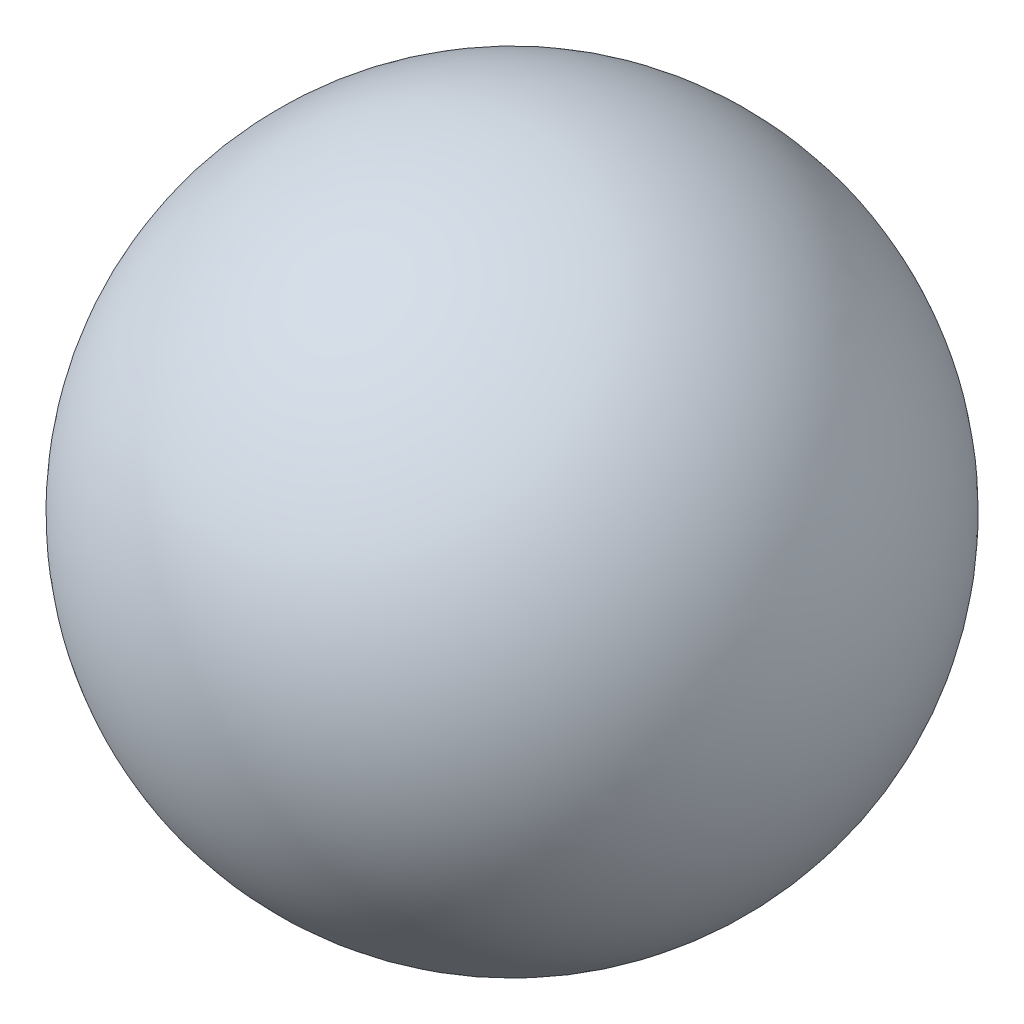
from build123d import *


with BuildPart() as part:
    # Sketch1 → Revolve1 (revolve)
    with BuildSketch(Plane(origin=(0, 0, 0), x_dir=(1, 0, 0), z_dir=(0, 1, 0))):
        with BuildLine():
            Line((0, 0), (0, 49))
            ThreePointArc((0, 49), (-24.5, 24.5), (0, 0))
        make_face()
    revolve(axis=Axis((0, 0, 0), (0, 0, -1)))


solid = part.part
